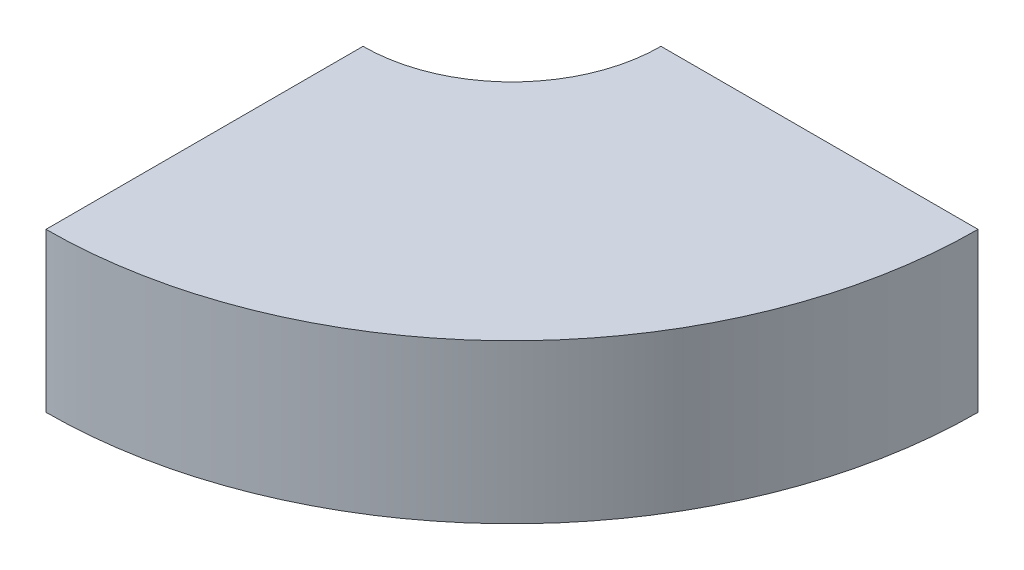
from build123d import *

# Parameters (mm, degrees)
BOSS_EXTRUDE1_DEPTH = 2


with BuildPart() as part:
    # Sketch2 → Boss-Extrude1 (new body)
    with BuildSketch(Plane(origin=(0, 0, 0), x_dir=(1, 0, 0), z_dir=(0, 1, 0))):
        with BuildLine():
            Line((1.88, 0), (5.88, 0))
            ThreePointArc((5.88, 0), (4.157787873, -4.157787873), (0, -5.88))
            Line((0, -5.88), (0, -1.88))
            ThreePointArc((0, -1.88), (1.329360749, -1.329360749), (1.88, 0))
        make_face()
    extrude(amount=BOSS_EXTRUDE1_DEPTH)


solid = part.part
